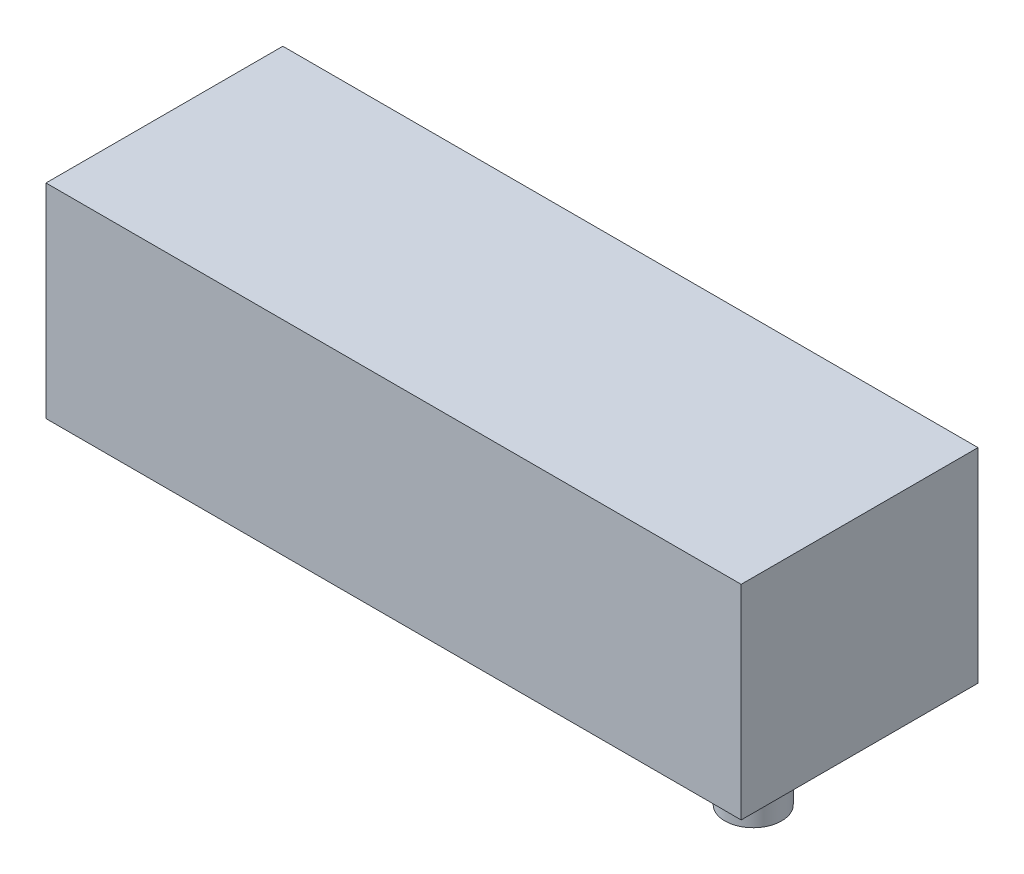
from build123d import *

# Parameters (mm, degrees)
SKETCH1_W           = 65.37
SKETCH1_H           = 19.19
BOSS_EXTRUDE1_DEPTH = 22.27
SKETCH2_R           = 2.665
BOSS_EXTRUDE2_DEPTH = 9.32


with BuildPart() as part:
    # Sketch1 → Boss-Extrude1 (new body)
    with BuildSketch(Plane.XY):
        with Locations((32.685, 9.595)):
            Rectangle(SKETCH1_W, SKETCH1_H)
    extrude(amount=-BOSS_EXTRUDE1_DEPTH)

    # Sketch2 → Boss-Extrude2 (add)
    with BuildSketch(Plane.XZ):
        with Locations((55.37, -11.135)):
            Circle(SKETCH2_R)
    extrude(amount=BOSS_EXTRUDE2_DEPTH)


solid = part.part
